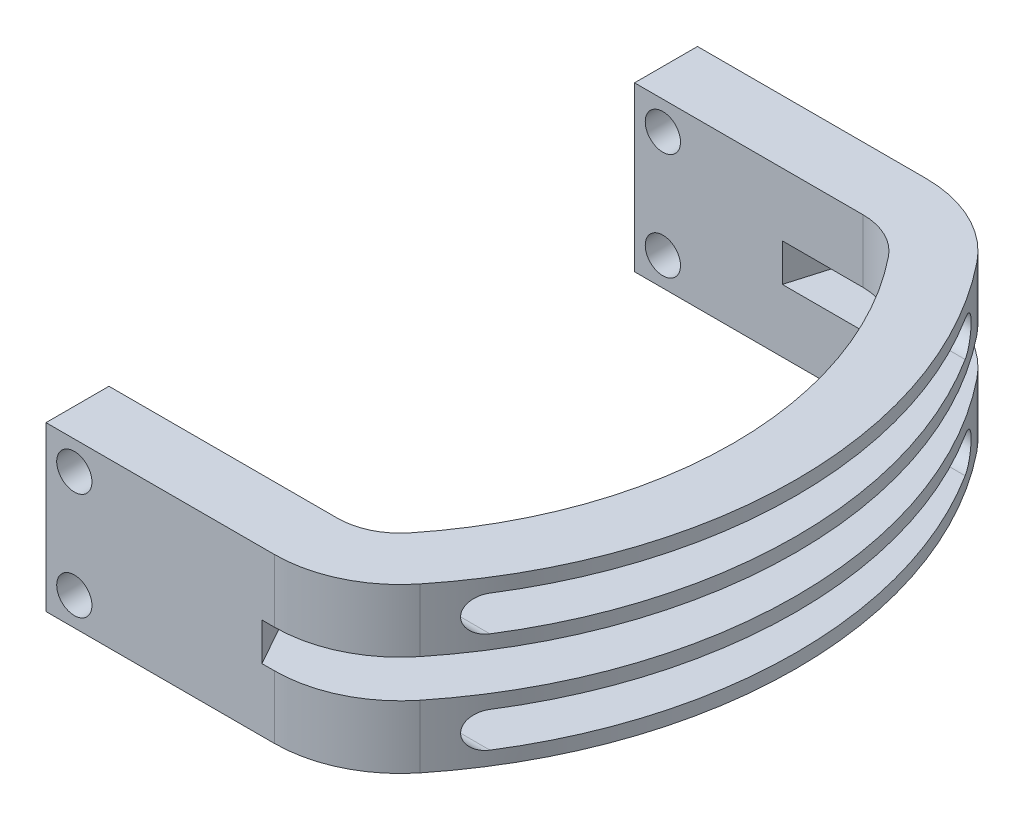
from build123d import *

# Parameters (mm, degrees)
RESSALTO_EXTRUS_O1_DEPTH   = 6.5
CORTE_EXTRUS_O1_DEPTH      = 34.71775564
CORTE_EXTRUS_O2_START      = -6.5
CORTE_EXTRUS_O2_DEPTH      = 1.5
ESBO_O5_R                  = 1.4
CORTE_EXTRUS_O3_DEPTH      = 47.75
CORTE_EXTRUS_O3_DEPTH_BACK = 6


with BuildPart() as part:
    # Esboço1 → Ressalto-extrusão1 (new body, symmetric)
    with BuildSketch(Plane(origin=(0, 0, 0), x_dir=(1, 0, 0), z_dir=(0, 1, 0))):
        with BuildLine():
            Line((0, 51.75), (18.140349372, 51.75))
            ThreePointArc((18.140349372, 51.75), (22.467809892, 50.765158648), (25.942897998, 48.004617089))
            ThreePointArc((25.942897998, 48.004617089), (33.71775564, 25.875), (25.942897998, 3.745382911))
            ThreePointArc((25.942897998, 3.745382911), (22.467809892, 0.984841352), (18.140349372, 0))
            Line((18.140349372, 0), (0, 0))
            Line((0, 0), (0, 5))
            Line((0, 5), (18.140349372, 5))
            ThreePointArc((18.140349372, 5), (20.304079632, 5.492420676), (22.041623685, 6.872691455))
            ThreePointArc((22.041623685, 6.872691455), (28.71775564, 25.875), (22.041623685, 44.877308545))
            ThreePointArc((22.041623685, 44.877308545), (20.304079632, 46.257579324), (18.140349372, 46.75))
            Line((18.140349372, 46.75), (0, 46.75))
            Line((0, 46.75), (0, 51.75))
        make_face()
    extrude(amount=RESSALTO_EXTRUS_O1_DEPTH, both=True)

    # Esboço2 → Corte-extrusão1 (cut, through all)
    with BuildSketch(Plane.ZY):
        with BuildLine():
            Line((-44.75, 2.6), (-7, 2.6))
            ThreePointArc((-7, 2.6), (-5.6, 4), (-7, 5.4))
            Line((-7, 5.4), (-44.75, 5.4))
            ThreePointArc((-44.75, 5.4), (-46.15, 4), (-44.75, 2.6))
        make_face()
        with BuildLine():
            Line((-44.75, -5.4), (-7, -5.4))
            ThreePointArc((-7, -5.4), (-5.6, -4), (-7, -2.6))
            Line((-7, -2.6), (-44.75, -2.6))
            ThreePointArc((-44.75, -2.6), (-46.15, -4), (-44.75, -5.4))
        make_face()
    extrude(amount=-CORTE_EXTRUS_O1_DEPTH, mode=Mode.SUBTRACT)

    # Esboço4 → Corte-extrusão2 (cut, symmetric)
    with BuildSketch(Plane(origin=(0, 6.5, 0), x_dir=(1, 0, 0), z_dir=(0, 1, 0)).offset(CORTE_EXTRUS_O2_START)):
        with BuildLine():
            Line((8.48, 35.63), (13.203313178, 51.75))
            Line((13.203313178, 51.75), (33.71775564, 51.75))
            Line((33.71775564, 51.75), (33.71775564, 0))
            Line((33.71775564, 0), (17.161678374, 0))
            Line((17.161678374, 0), (11.37, 10.3))
            ThreePointArc((11.37, 10.3), (7.366682193, 22.673111391), (8.48, 35.63))
        make_face()
    extrude(amount=CORTE_EXTRUS_O2_DEPTH, both=True, mode=Mode.SUBTRACT)

    # Esboço5 → Corte-extrusão3 (cut, two sides)
    with BuildSketch(Plane.XY.offset(-46.75)) as corte_extrus_o3_sk:
        with Locations((2.25, 4.25)):
            Circle(ESBO_O5_R)
        with Locations((2.25, -4.25)):
            Circle(ESBO_O5_R)
    extrude(amount=CORTE_EXTRUS_O3_DEPTH, mode=Mode.SUBTRACT)
    extrude(corte_extrus_o3_sk.sketch, amount=-CORTE_EXTRUS_O3_DEPTH_BACK, mode=Mode.SUBTRACT)


solid = part.part
